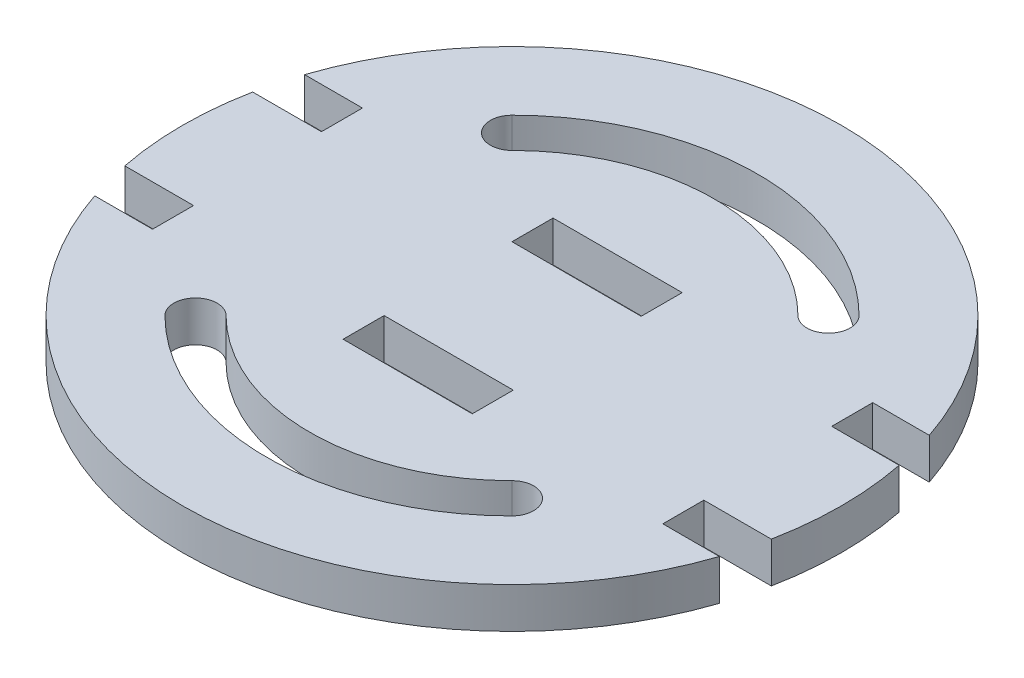
from build123d import *

# Parameters (mm, degrees)
SKETCH1_W           = 20.2
SKETCH1_H           = 6.4135
BOSS_EXTRUDE1_DEPTH = 6.35
CUT_EXTRUDE1_DEPTH  = 7.35


with BuildPart() as part:
    # Sketch1 → Boss-Extrude1 (new body)
    with BuildSketch(Plane(origin=(0, 0, 0), x_dir=(1, 0, 0), z_dir=(0, 1, 0))):
        with BuildLine():
            ThreePointArc((48.846590956, 16.4135), (0, 51.5305), (-48.846590956, 16.4135))
            Line((-48.846590956, 16.4135), (-39.8, 16.4135))
            Line((-39.8, 16.4135), (-39.8, 10))
            Line((-39.8, 10), (-50.55088951, 10))
            ThreePointArc((-50.55088951, 10), (-51.5305, 0), (-50.55088951, -10))
            Line((-50.55088951, -10), (-39.8, -10))
            Line((-39.8, -10), (-39.8, -16.4135))
            Line((-39.8, -16.4135), (-48.846590956, -16.4135))
            ThreePointArc((-48.846590956, -16.4135), (0, -51.5305), (48.846590956, -16.4135))
            Line((48.846590956, -16.4135), (40, -16.4135))
            Line((40, -16.4135), (40, -10))
            Line((40, -10), (50.55088951, -10))
            ThreePointArc((50.55088951, -10), (51.285012636, -5.023933636), (51.5305, 0))
            ThreePointArc((51.5305, 0), (51.285012636, 5.023933636), (50.55088951, 10))
            Line((50.55088951, 10), (40, 10))
            Line((40, 10), (40, 16.4135))
            Line((40, 16.4135), (48.846590956, 16.4135))
        make_face()
        with Locations((0.1, -13.20675)):
            Rectangle(SKETCH1_W, SKETCH1_H, mode=Mode.SUBTRACT)
        with Locations((0.1, 13.20675)):
            Rectangle(SKETCH1_W, SKETCH1_H, mode=Mode.SUBTRACT)
    extrude(amount=BOSS_EXTRUDE1_DEPTH)

    # Sketch2 → Cut-Extrude1 (cut, through all)
    with BuildSketch(Plane(origin=(0, 6.35, 0), x_dir=(1, 0, 0), z_dir=(0, 1, 0))):
        with BuildLine():
            ThreePointArc((-27.13748547, -27.13748547), (0, -38.3782), (27.13748547, -27.13748547))
            ThreePointArc((27.13748547, -27.13748547), (27.13748547, -22.359989213), (22.359989213, -22.359989213))
            ThreePointArc((22.359989213, -22.359989213), (0, -31.6218), (-22.359989213, -22.359989213))
            ThreePointArc((-22.359989213, -22.359989213), (-27.13748547, -22.359989213), (-27.13748547, -27.13748547))
        make_face()
        with BuildLine():
            ThreePointArc((-27.13748547, 27.13748547), (0, 38.3782), (27.13748547, 27.13748547))
            ThreePointArc((27.13748547, 27.13748547), (27.13748547, 22.359989213), (22.359989213, 22.359989213))
            ThreePointArc((22.359989213, 22.359989213), (0, 31.6218), (-22.359989213, 22.359989213))
            ThreePointArc((-22.359989213, 22.359989213), (-27.13748547, 22.359989213), (-27.13748547, 27.13748547))
        make_face()
    extrude(amount=-CUT_EXTRUDE1_DEPTH, mode=Mode.SUBTRACT)


solid = part.part
